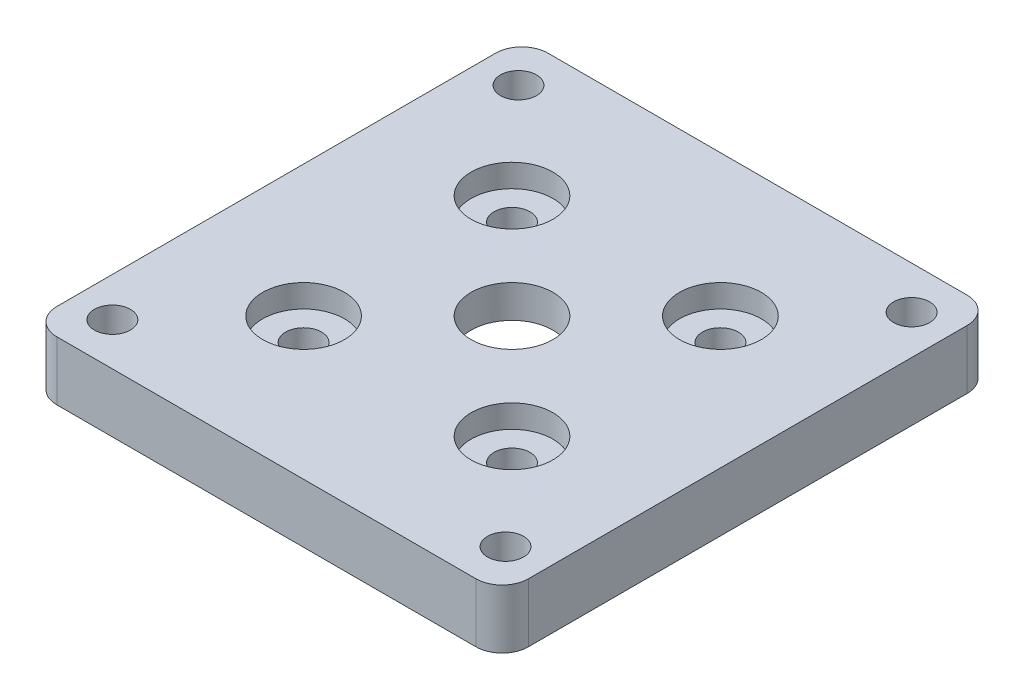
from build123d import *

# Parameters (mm, degrees)
SKETCH1_W           = 72
SKETCH1_H           = 75
SKETCH1_R           = 2.75
SKETCH1_R_2         = 6.25
BOSS_EXTRUDE3_DEPTH = 9
FILLET1_R           = 4
SKETCH4_R           = 16.25
CUT_EXTRUDE2_DEPTH  = 4
SKETCH3_R           = 6.25
CUT_EXTRUDE3_DEPTH  = 3.5


with BuildPart() as part:
    # Sketch1 → Boss-Extrude3 (new body)
    with BuildSketch(Plane(origin=(0, 0, 0), x_dir=(1, 0, 0), z_dir=(0, 1, 0))):
        with Locations((30.01, -31)):
            Rectangle(SKETCH1_W, SKETCH1_H)
        Circle(SKETCH1_R, mode=Mode.SUBTRACT)
        with Locations((60.02, 0)):
            Circle(SKETCH1_R, mode=Mode.SUBTRACT)
        with Locations((60.02, -62)):
            Circle(SKETCH1_R, mode=Mode.SUBTRACT)
        with Locations((0, -62)):
            Circle(SKETCH1_R, mode=Mode.SUBTRACT)
        with Locations((30.01, -31)):
            Circle(SKETCH1_R_2, mode=Mode.SUBTRACT)
        with Locations((14.100097423, -15.090097423)):
            Circle(SKETCH1_R, mode=Mode.SUBTRACT)
        with Locations((14.100097423, -46.909902577)):
            Circle(SKETCH1_R, mode=Mode.SUBTRACT)
        with Locations((45.919902577, -46.909902577)):
            Circle(SKETCH1_R, mode=Mode.SUBTRACT)
        with Locations((45.919902577, -15.090097423)):
            Circle(SKETCH1_R, mode=Mode.SUBTRACT)
    extrude(amount=BOSS_EXTRUDE3_DEPTH)

    # Fillet1
    fillet1_edges = [part.edges().sort_by_distance(p)[0] for p in [
        (66.01, 4.5, 68.5),
        (-5.99, 4.5, 68.5),
        (-5.99, 4.5, -6.5),
        (66.01, 4.5, -6.5),
    ]]
    fillet(fillet1_edges, radius=FILLET1_R)

    # Sketch4 → Cut-Extrude2 (cut)
    with BuildSketch(Plane.XZ):
        with Locations((30.01, 31)):
            Circle(SKETCH4_R)
    extrude(amount=-CUT_EXTRUDE2_DEPTH, mode=Mode.SUBTRACT)

    # Sketch3 → Cut-Extrude3 (cut)
    with BuildSketch(Plane(origin=(0, 9, 0), x_dir=(1, 0, 0), z_dir=(0, 1, 0))):
        with Locations((14.100097423, -46.909902577)):
            Circle(SKETCH3_R)
        with Locations((14.100097423, -15.090097423)):
            Circle(SKETCH3_R)
        with Locations((45.919902577, -15.090097423)):
            Circle(SKETCH3_R)
        with Locations((45.919902577, -46.909902577)):
            Circle(SKETCH3_R)
    extrude(amount=-CUT_EXTRUDE3_DEPTH, mode=Mode.SUBTRACT)


solid = part.part
